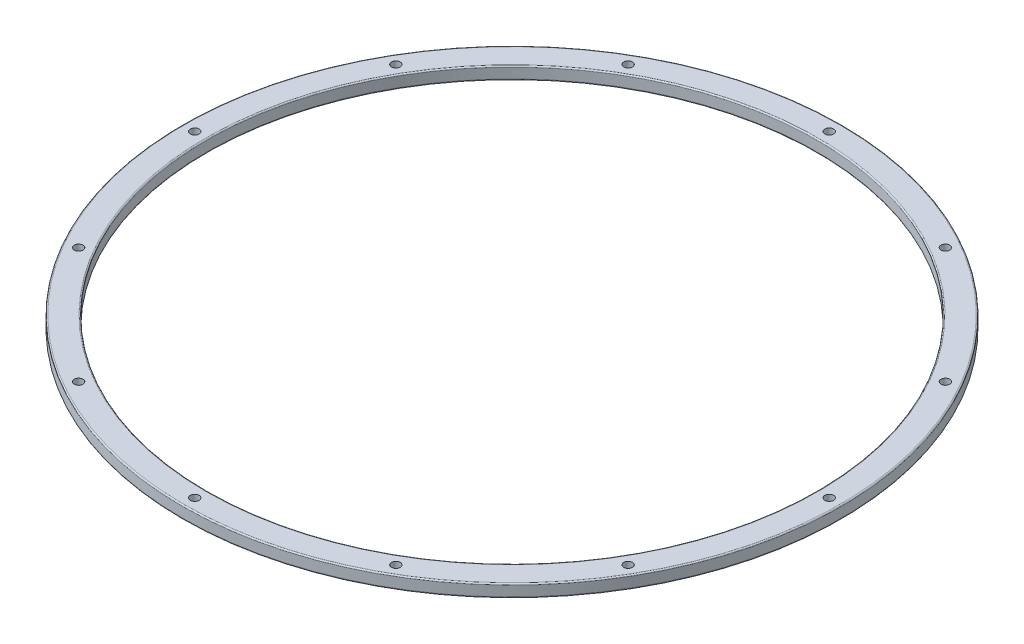
from build123d import *

# Parameters (mm, degrees)
F_44_0_086_DIAMETER_HOLE1_D = 2.1844
SCREW_PASSTHROUGHS_COUNT    = 12


with BuildPart() as part:
    # Sketch1 → Main (revolve)
    with BuildSketch(Plane.XY):
        with BuildLine():
            Line((-76.5175, 0), (-82.042, 0))
            ThreePointArc((-82.042, 0), (-82.266506403, 0.092993597), (-82.3595, 0.3175))
            Line((-82.3595, 0.3175), (-82.3595, 2.8575))
            ThreePointArc((-82.3595, 2.8575), (-82.266506403, 3.082006403), (-82.042, 3.175))
            Line((-82.042, 3.175), (-76.5175, 3.175))
            ThreePointArc((-76.5175, 3.175), (-76.292993597, 3.082006403), (-76.2, 2.8575))
            Line((-76.2, 2.8575), (-76.2, 0.3175))
            ThreePointArc((-76.2, 0.3175), (-76.292993597, 0.092993597), (-76.5175, 0))
        make_face()
    revolve(axis=Axis((0, 55, 0), (0, -1, 0)))

    # #44 (0.086) Diameter Hole1 (through all)
    with Locations(Plane(origin=(0, 0, 0), x_dir=(-1, 0, 0), z_dir=(0, -1, 0))):
        with Locations((79.27975, 0)):
            f_44_0_086_diameter_hole1 = Hole(F_44_0_086_DIAMETER_HOLE1_D / 2)

    # Screw Passthroughs: #44 (0.086) Diameter Hole1 ×12 about axis
    screw_passthroughs_axis = Axis((0, 0, 0), (0, 1, 0))
    for i in range(1, SCREW_PASSTHROUGHS_COUNT):
        add(f_44_0_086_diameter_hole1.rotate(screw_passthroughs_axis, i * 360 / SCREW_PASSTHROUGHS_COUNT), mode=Mode.SUBTRACT)


solid = part.part
